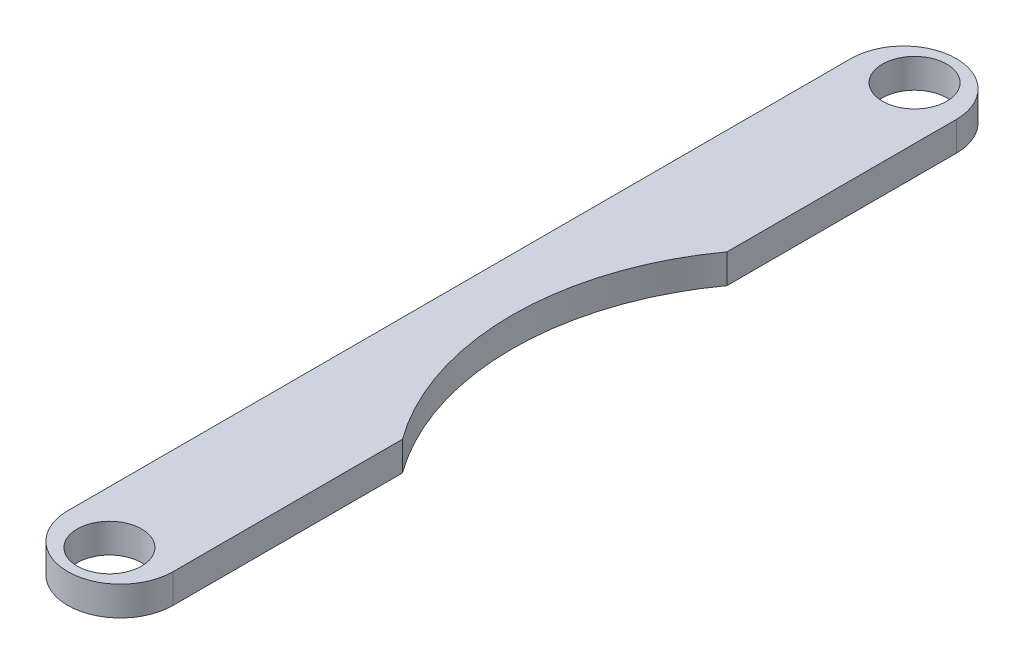
from build123d import *

# Parameters (mm, degrees)
SKETCH1_R               = 1.1
BOSS_EXTRUDE1_DEPTH     = 1
SKETCH3_R               = 12.7
CUT_EXTRUDE1_DEPTH      = 2.979898987
CUT_EXTRUDE1_DEPTH_BACK = 2.272792206
CUT_EXTRUDE2_REACH      = 3
SKETCH4_R               = 9.430256121


with BuildPart() as part:
    # Sketch1 → Boss-Extrude1 (new body)
    with BuildSketch(Plane(origin=(0, 0, 0), x_dir=(1, 0, 0), z_dir=(0, 1, 0))):
        with BuildLine():
            Line((-1.8, -13.375), (-1.8, 13.375))
            ThreePointArc((-1.8, 13.375), (0, 15.175), (1.8, 13.375))
            Line((1.8, 13.375), (1.8, -13.375))
            ThreePointArc((1.8, -13.375), (0, -15.175), (-1.8, -13.375))
        make_face()
        with Locations((0, -13.75)):
            Circle(SKETCH1_R, mode=Mode.SUBTRACT)
        with Locations((0, 13.75)):
            Circle(SKETCH1_R, mode=Mode.SUBTRACT)
    extrude(amount=BOSS_EXTRUDE1_DEPTH)

    # Sketch3 → Cut-Extrude1 (cut, two sides)
    with BuildSketch(Plane(origin=(0, 0, 0), x_dir=(0.707106781, -0.707106781, 0), z_dir=(0.707106781, 0.707106781, 0))) as cut_extrude1_sk:
        with Locations((12.7, 0)):
            Circle(SKETCH3_R)
    extrude(amount=CUT_EXTRUDE1_DEPTH, mode=Mode.SUBTRACT)
    extrude(cut_extrude1_sk.sketch, amount=-CUT_EXTRUDE1_DEPTH_BACK, mode=Mode.SUBTRACT)

    # Sketch4 → Cut-Extrude2 (cut, up to next)
    with BuildSketch(Plane.XZ, mode=Mode.PRIVATE) as cut_extrude2_sk1:
        with Locations((9.430256121, 0)):
            Circle(SKETCH4_R)
    cut_extrude2_tool1 = extrude(cut_extrude2_sk1.sketch, amount=-CUT_EXTRUDE2_REACH, mode=Mode.PRIVATE) & part.part
    add(cut_extrude2_tool1.solids().sort_by_distance((9.430256, 0, 0))[0], mode=Mode.SUBTRACT)


solid = part.part
